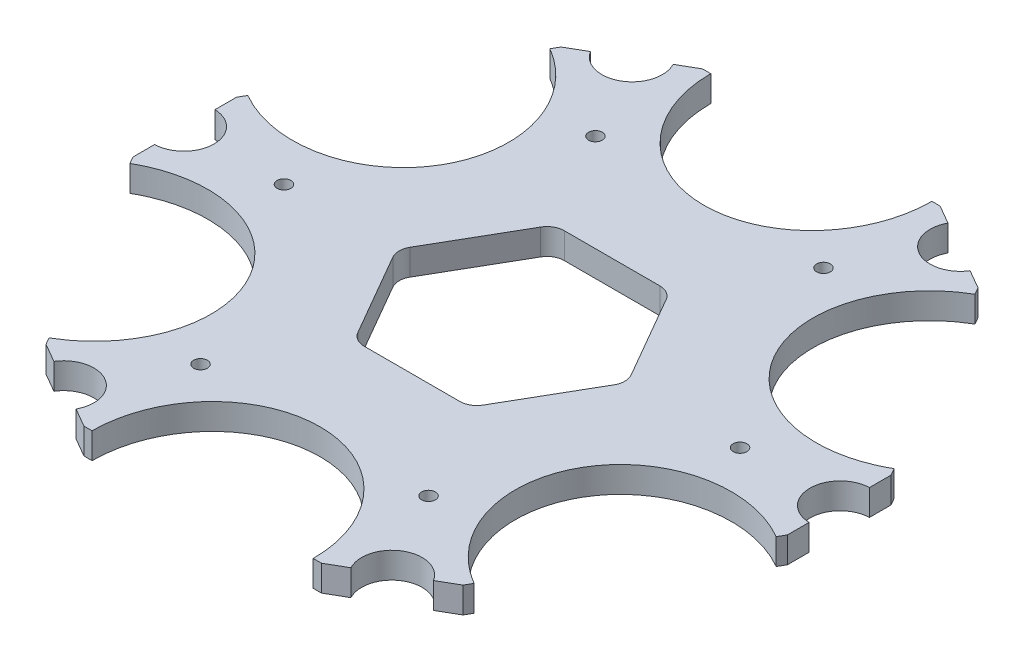
from build123d import *

# Parameters (mm, degrees)
SKETCH1_R           = 12.7
BOSS_EXTRUDE1_DEPTH = 2.38125
CUT_EXTRUDE1_DEPTH  = 5.7625
FILLET1_R           = 3.175
SKETCH3_RX          = 21.59
SKETCH3_RY          = 20.32
CUT_EXTRUDE2_DEPTH  = 5.7625
CIRPATTERN1_COUNT   = 6
SKETCH4_R           = 1.27
CUT_EXTRUDE3_DEPTH  = 5.7625001
CIRPATTERN2_COUNT   = 6


with BuildPart() as part:
    # Sketch1 → Boss-Extrude1 (new body, symmetric)
    with BuildSketch(Plane(origin=(0, 0, 0), x_dir=(1, 0, 0), z_dir=(0, 1, 0))):
        with BuildLine():
            Line((-60.1472, 5.553404471), (-60.1472, 9.525))
            Line((-60.1472, 9.525), (-38.322491971, 47.326503167))
            Line((-38.322491971, 47.326503167), (-34.88298935, 49.312300931))
            ThreePointArc((-34.88298935, 49.312300931), (-27.384375, 47.431128834), (-25.26421065, 54.865705402))
            Line((-25.26421065, 54.865705402), (-21.824708029, 56.851503167))
            Line((-21.824708029, 56.851503167), (21.824708029, 56.851503167))
            Line((21.824708029, 56.851503167), (25.26421065, 54.865705402))
            ThreePointArc((25.26421065, 54.865705402), (27.384375, 47.431128834), (34.88298935, 49.312300931))
            Line((34.88298935, 49.312300931), (38.322491971, 47.326503167))
            Line((38.322491971, 47.326503167), (60.1472, 9.525))
            Line((60.1472, 9.525), (60.1472, 5.553404471))
            ThreePointArc((60.1472, 5.553404471), (54.76875, 0), (60.1472, -5.553404471))
            Line((60.1472, -5.553404471), (60.1472, -9.525))
            Line((60.1472, -9.525), (38.322491971, -47.326503167))
            Line((38.322491971, -47.326503167), (34.88298935, -49.312300931))
            ThreePointArc((34.88298935, -49.312300931), (27.384375, -47.431128834), (25.26421065, -54.865705402))
            Line((25.26421065, -54.865705402), (21.824708029, -56.851503167))
            Line((21.824708029, -56.851503167), (-21.824708029, -56.851503167))
            Line((-21.824708029, -56.851503167), (-25.26421065, -54.865705402))
            ThreePointArc((-25.26421065, -54.865705402), (-27.384375, -47.431128834), (-34.88298935, -49.312300931))
            Line((-34.88298935, -49.312300931), (-38.322491971, -47.326503167))
            Line((-38.322491971, -47.326503167), (-60.1472, -9.525))
            Line((-60.1472, -9.525), (-60.1472, -5.553404471))
            ThreePointArc((-60.1472, -5.553404471), (-54.76875, 0), (-60.1472, 5.553404471))
        make_face()
        Circle(SKETCH1_R, mode=Mode.SUBTRACT)
    extrude(amount=BOSS_EXTRUDE1_DEPTH, both=True)

    # Sketch2 → Cut-Extrude1 (cut, through all)
    with BuildSketch(Plane(origin=(0, 2.38125, 0), x_dir=(1, 0, 0), z_dir=(0, 1, 0))):
        Polygon((10.61724051, -18.3896), (21.234481021, 0), (10.61724051, 18.3896), (-10.61724051, 18.3896), (-21.234481021, 0), (-10.61724051, -18.3896), align=None)
    extrude(amount=-CUT_EXTRUDE1_DEPTH, mode=Mode.SUBTRACT)

    # Fillet1
    fillet1_edges = [part.edges().sort_by_distance(p)[0] for p in [
        (10.61724051, 0, 18.3896),
        (-10.61724051, 0, 18.3896),
        (-21.234481021, 0, 0),
        (-10.61724051, 0, -18.3896),
        (10.61724051, 0, -18.3896),
        (21.234481021, 0, 0),
    ]]
    fillet(fillet1_edges, radius=FILLET1_R)

    # Sketch3 → Cut-Extrude2 (cut, through all)
    with BuildSketch(Plane(origin=(0, 2.38125, 0), x_dir=(1, 0, 0), z_dir=(0, 1, 0))):
        with Locations(Location((0, -56.851503167), (0, 0, -90))):
            Ellipse(SKETCH3_RX, SKETCH3_RY)
    cut_extrude2 = extrude(amount=-CUT_EXTRUDE2_DEPTH, mode=Mode.SUBTRACT)

    # CirPattern1: Cut-Extrude2 ×6 about axis
    cirpattern1_axis = Axis((0, -2.619375, 0), (0, 1, 0))
    for i in range(1, CIRPATTERN1_COUNT):
        add(cut_extrude2.rotate(cirpattern1_axis, i * 360 / CIRPATTERN1_COUNT), mode=Mode.SUBTRACT)

    # Sketch4 → Cut-Extrude3 (cut, through all)
    with BuildSketch(Plane(origin=(0, 2.38125, 0), x_dir=(1, 0, 0), z_dir=(0, 1, 0))):
        with Locations((41.91, 0)):
            Circle(SKETCH4_R)
    cut_extrude3 = extrude(amount=-CUT_EXTRUDE3_DEPTH, mode=Mode.SUBTRACT)

    # CirPattern2: Cut-Extrude3 ×6 about axis
    cirpattern2_axis = Axis((0, 0, 0), (0, 1, 0))
    for i in range(1, CIRPATTERN2_COUNT):
        add(cut_extrude3.rotate(cirpattern2_axis, i * 360 / CIRPATTERN2_COUNT), mode=Mode.SUBTRACT)


solid = part.part
